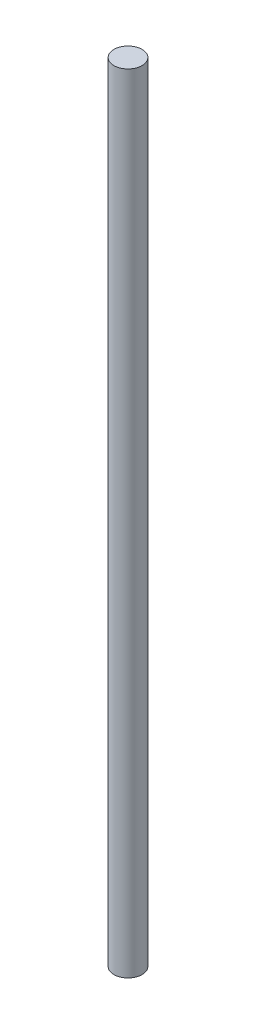
from build123d import *

# Parameters (mm, degrees)
SKETCH1_R           = 2.5
BOSS_EXTRUDE1_DEPTH = 140


with BuildPart() as part:
    # Sketch1 → Boss-Extrude1 (new body)
    with BuildSketch(Plane(origin=(0, 0, 0), x_dir=(1, 0, 0), z_dir=(0, 1, 0))):
        Circle(SKETCH1_R)
    extrude(amount=BOSS_EXTRUDE1_DEPTH)


solid = part.part
